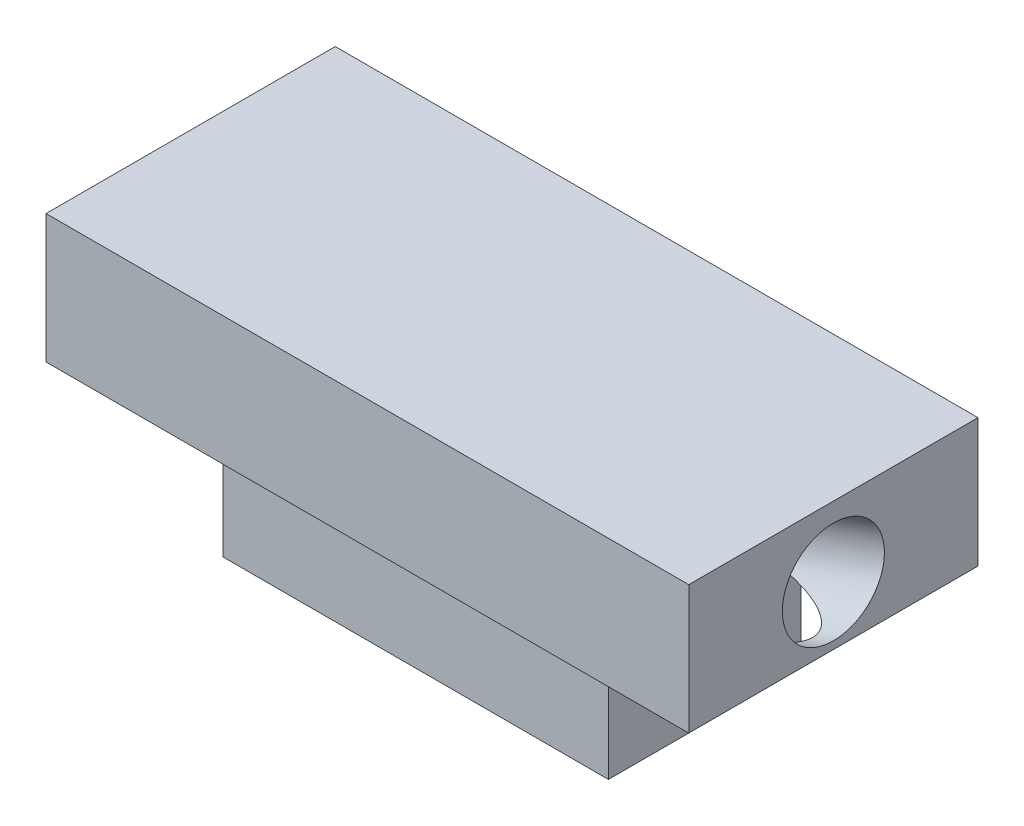
from build123d import *

# Parameters (mm, degrees)
SKETCH1_W           = 3
SKETCH1_H           = 1.5
BOSS_EXTRUDE1_DEPTH = 1
SKETCH5_W           = 5
SKETCH5_H           = 2.25
BOSS_EXTRUDE2_DEPTH = 1
SKETCH4_R           = 0.396875


with BuildPart() as part:
    # Sketch1 → Boss-Extrude1 (new body)
    with BuildSketch(Plane(origin=(0, 0, 0), x_dir=(1, 0, 0), z_dir=(0, 1, 0))):
        with Locations((0.462795252, 0.4015625)):
            Rectangle(SKETCH1_W, SKETCH1_H)
    extrude(amount=BOSS_EXTRUDE1_DEPTH)

    # Sketch5 → Boss-Extrude2 (add)
    with BuildSketch(Plane(origin=(0, 1, 0), x_dir=(1, 0, 0), z_dir=(0, 1, 0))):
        with Locations((0.462795252, 0.4015625)):
            Rectangle(SKETCH5_W, SKETCH5_H)
    extrude(amount=BOSS_EXTRUDE2_DEPTH)

    # Cut-Sweep3: sweep along a path in Sketch2
    with BuildLine(Plane.XY) as cut_sweep3_path:
        Line((-1.037204748, 0), (4.752109832, 2.107138184))
    # Sketch4 → Cut-Sweep3 (sweep, cut)
    with BuildSketch(Plane(origin=(-1.037204748, 1, 0), x_dir=(0, 0, 1), z_dir=(-1, 0, 0))):
        with Locations((-0.4015625, -1)):
            Circle(SKETCH4_R)
    sweep(path=cut_sweep3_path.line, mode=Mode.SUBTRACT)


solid = part.part
